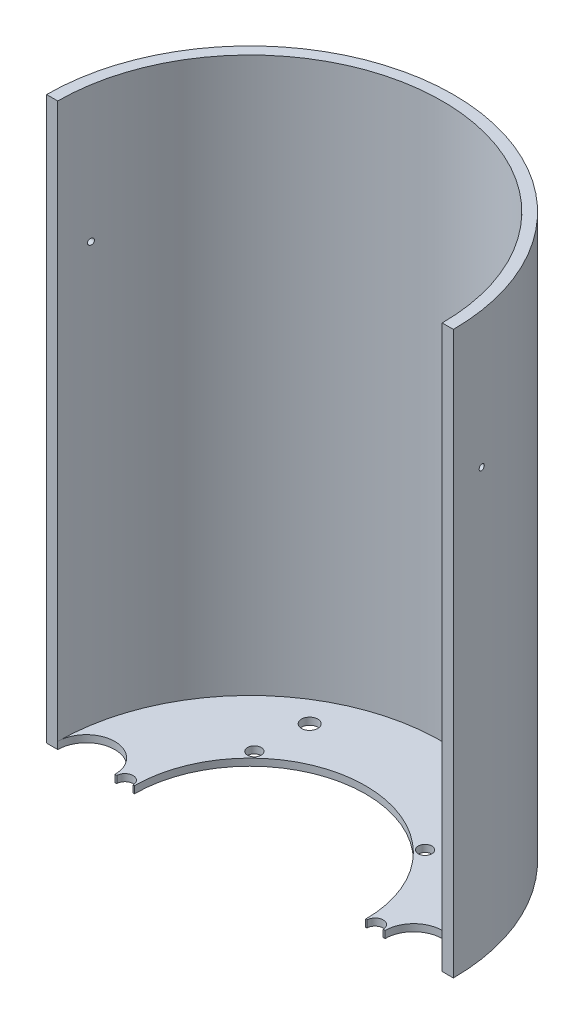
from build123d import *

# Parameters (mm, degrees)
SKETCH1_R               = 94.996
SKETCH1_R_2             = 53.975
TOP_OF_HATCH_DEPTH      = 3.302
SKETCH2_R               = 94.996
SKETCH2_R_2             = 89.789
HATCH_BODY_DEPTH        = 259.08
SKETCH3_R               = 13.335
CHARGE_TUBE_HOLES_DEPTH = 263.382
SKETCH4_R               = 3.81
BOLT_HOLES_DEPTH        = 263.382
SKETCH_5_R              = 5.08
ANTENNA_HOLES_DEPTH     = 263.382
SKETCH5_R               = 3.81
SKETCH5_R_2             = 3.175
INNER_SCREW_HOLES_DEPTH = 263.382
SKETCH8_R               = 1.397
CUT_EXTRUDE1_DEPTH      = 190.992
CUT_EXTRUDE3_DEPTH      = 263.3820001


with BuildPart() as part:
    # Sketch1 → Top of Hatch (new body)
    with BuildSketch(Plane(origin=(0, 0, 0), x_dir=(1, 0, 0), z_dir=(0, 1, 0))):
        Circle(SKETCH1_R)
        Circle(SKETCH1_R_2, mode=Mode.SUBTRACT)
    extrude(amount=TOP_OF_HATCH_DEPTH)

    # Sketch2 → Hatch Body (add)
    with BuildSketch(Plane(origin=(0, 3.302, 0), x_dir=(1, 0, 0), z_dir=(0, 1, 0))):
        Circle(SKETCH2_R)
        Circle(SKETCH2_R_2, mode=Mode.SUBTRACT)
    extrude(amount=HATCH_BODY_DEPTH)

    # Sketch3 → Charge Tube Holes (cut, through all)
    with BuildSketch(Plane.XZ):
        with Locations((-76.454, 0)):
            Circle(SKETCH3_R)
        with Locations((76.454, 0)):
            Circle(SKETCH3_R)
    extrude(amount=-CHARGE_TUBE_HOLES_DEPTH, mode=Mode.SUBTRACT)

    # Sketch4 → Bolt Holes (cut, through all)
    with BuildSketch(Plane.XZ):
        with Locations((-38.1, -65.991135768)):
            Circle(SKETCH4_R)
        with Locations((-38.1, 65.991135768)):
            Circle(SKETCH4_R)
        with Locations((38.1, 65.991135768)):
            Circle(SKETCH4_R)
        with Locations((38.1, -65.991135768)):
            Circle(SKETCH4_R)
    extrude(amount=-BOLT_HOLES_DEPTH, mode=Mode.SUBTRACT)

    # Sketch 5 → Antenna Holes (cut, through all)
    with BuildSketch(Plane.XZ):
        with Locations((-26.112352144, 57.324838678)):
            Circle(SKETCH_5_R)
        with Locations((9.193647856, 61.033450854)):
            Circle(SKETCH_5_R)
    extrude(amount=-ANTENNA_HOLES_DEPTH, mode=Mode.SUBTRACT)

    # Sketch5 → Inner Screw Holes (cut, through all)
    with BuildSketch(Plane.XZ):
        with Locations((58.42, 0)):
            Circle(SKETCH5_R)
        with Locations((-58.42, 0)):
            Circle(SKETCH5_R)
        with Locations((39.878, 41.91)):
            Circle(SKETCH5_R_2)
        with Locations((-39.878, 41.91)):
            Circle(SKETCH5_R_2)
        with Locations((39.878, -41.91)):
            Circle(SKETCH5_R_2)
        with Locations((-39.878, -41.91)):
            Circle(SKETCH5_R_2)
    extrude(amount=-INNER_SCREW_HOLES_DEPTH, mode=Mode.SUBTRACT)

    # Sketch8 → Cut-Extrude1 (cut, through all)
    with BuildSketch(Plane(origin=(94.996, 0, 0), x_dir=(0, 0, -1), z_dir=(1, 0, 0))):
        with Locations((14.351, 198.882)):
            Circle(SKETCH8_R)
        with Locations((-14.351, 198.882)):
            Circle(SKETCH8_R)
    extrude(amount=-CUT_EXTRUDE1_DEPTH, mode=Mode.SUBTRACT)

    # Sketch12 → Cut-Extrude3 (cut, through all)
    with BuildSketch(Plane.XZ):
        with BuildLine():
            Line((-94.996, 0), (94.996, 0))
            ThreePointArc((94.996, 0), (0, 94.996), (-94.996, 0))
        make_face()
    extrude(amount=-CUT_EXTRUDE3_DEPTH, mode=Mode.SUBTRACT)


solid = part.part
